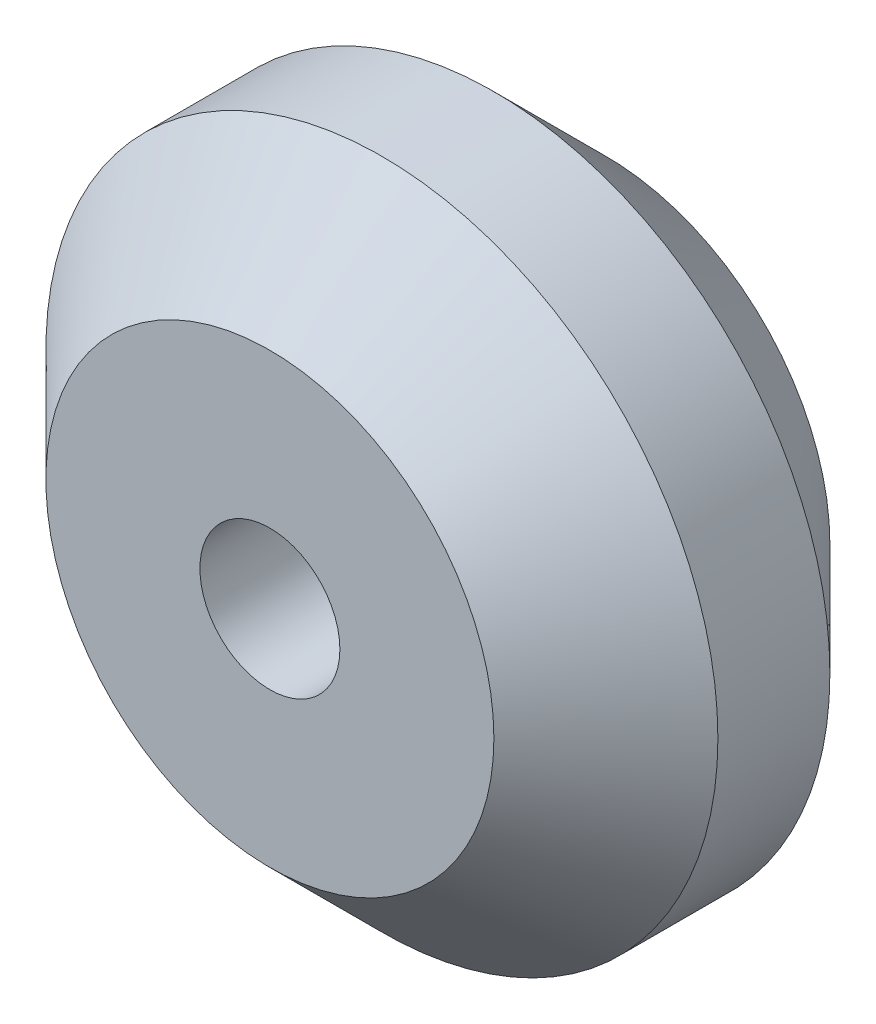
from build123d import *

# Parameters (mm, degrees)
SKETCH1_R           = 12
SKETCH1_R_2         = 2.5
BOSS_EXTRUDE1_DEPTH = 12
CHAMFER1_SIZE       = 4


with BuildPart() as part:
    # Sketch1 → Boss-Extrude1 (new body)
    with BuildSketch(Plane.XY):
        Circle(SKETCH1_R)
        Circle(SKETCH1_R_2, mode=Mode.SUBTRACT)
    extrude(amount=BOSS_EXTRUDE1_DEPTH)

    # Chamfer1
    chamfer1_edges = [part.edges().sort_by_distance(p)[0] for p in [
        (-12, 0, 0),
        (-12, 0, 12),
    ]]
    chamfer(chamfer1_edges, length=CHAMFER1_SIZE)


solid = part.part
